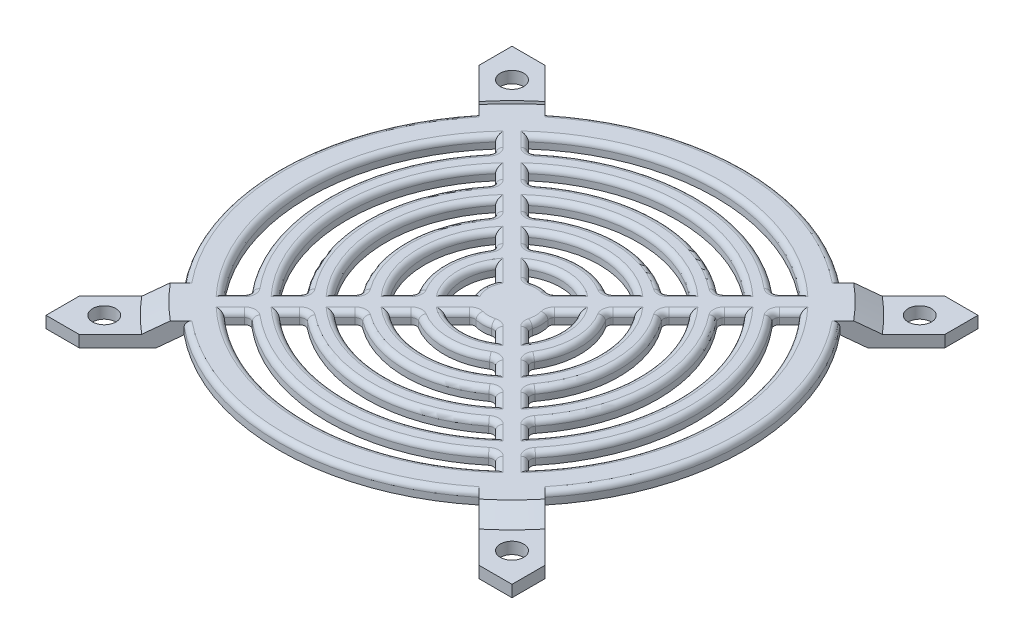
from build123d import *

# Parameters (mm, degrees)
SKETCH_1_R          = 3
EXTRUDE_1_DEPTH     = 6
SKETCH_2_R          = 65
CUT_EXTRUDE_1_DEPTH = 3
CUT_EXTRUDE_1_DRAFT = -60
SKETCH_3_OUTSIDE_W  = 166.354
SKETCH_3_OUTSIDE_H  = 166.354
SKETCH_3_OUTSIDE_R  = 62.5
CUT_EXTRUDE_2_DEPTH = 3
CUT_EXTRUDE_2_DRAFT = -60
FILLET_1_R          = 1.4


with BuildPart() as part:
    # Эскиз1 → Бобышка-Вытянуть1 (new body)
    with BuildSketch(Plane(origin=(0, 0, 0), x_dir=(1, 0, 0), z_dir=(0, 1, 0))):
        with BuildLine():
            Line((-51.514718626, -60), (-37.971101151, -46.456382526))
            ThreePointArc((-37.971101151, -46.456382526), (0, -60), (37.971101151, -46.456382526))
            Line((37.971101151, -46.456382526), (51.514718626, -60))
            Line((51.514718626, -60), (60, -60))
            Line((60, -60), (60, -51.514718626))
            Line((60, -51.514718626), (46.456382526, -37.971101151))
            ThreePointArc((46.456382526, -37.971101151), (60, 0), (46.456382526, 37.971101151))
            Line((46.456382526, 37.971101151), (60, 51.514718626))
            Line((60, 51.514718626), (60, 60))
            Line((60, 60), (51.514718626, 60))
            Line((51.514718626, 60), (37.971101151, 46.456382526))
            ThreePointArc((37.971101151, 46.456382526), (0, 60), (-37.971101151, 46.456382526))
            Line((-37.971101151, 46.456382526), (-51.514718626, 60))
            Line((-51.514718626, 60), (-60, 60))
            Line((-60, 60), (-60, 51.514718626))
            Line((-60, 51.514718626), (-46.456382526, 37.971101151))
            ThreePointArc((-46.456382526, 37.971101151), (-60, 0), (-46.456382526, -37.971101151))
            Line((-46.456382526, -37.971101151), (-60, -51.514718626))
            Line((-60, -51.514718626), (-60, -60))
            Line((-60, -60), (-51.514718626, -60))
        make_face()
        with Locations(Location((-52.5, -52.5, 0), (0, 0, 270))):
            Circle(SKETCH_1_R, mode=Mode.SUBTRACT)
        with Locations(Location((-52.5, 52.5, 0), (0, 0, 270))):
            Circle(SKETCH_1_R, mode=Mode.SUBTRACT)
        with Locations(Location((52.5, 52.5, 0), (0, 0, 270))):
            Circle(SKETCH_1_R, mode=Mode.SUBTRACT)
        with Locations(Location((52.5, -52.5, 0), (0, 0, 270))):
            Circle(SKETCH_1_R, mode=Mode.SUBTRACT)
        with BuildLine():
            Line((14.312505684, 10.069864997), (17.889167375, 13.646526688))
            ThreePointArc((17.889167375, 13.646526688), (22.5, 0), (17.889167375, -13.646526688))
            Line((17.889167375, -13.646526688), (14.312505684, -10.069864997))
            ThreePointArc((14.312505684, -10.069864997), (17.5, 0), (14.312505684, 10.069864997))
        make_face(mode=Mode.SUBTRACT)
        with BuildLine():
            Line((2.73923518, -6.981875867), (6.459180807, -10.701821494))
            ThreePointArc((6.459180807, -10.701821494), (0, -12.5), (-6.459180807, -10.701821494))
            Line((-6.459180807, -10.701821494), (-2.73923518, -6.981875867))
            ThreePointArc((-2.73923518, -6.981875867), (0, -7.5), (2.73923518, -6.981875867))
        make_face(mode=Mode.SUBTRACT)
        with BuildLine():
            Line((6.981875867, -2.73923518), (10.701821494, -6.459180807))
            ThreePointArc((10.701821494, -6.459180807), (12.5, 0), (10.701821494, 6.459180807))
            Line((10.701821494, 6.459180807), (6.981875867, 2.73923518))
            ThreePointArc((6.981875867, 2.73923518), (7.5, 0), (6.981875867, -2.73923518))
        make_face(mode=Mode.SUBTRACT)
        with BuildLine():
            Line((2.73923518, 6.981875867), (6.459180807, 10.701821494))
            ThreePointArc((6.459180807, 10.701821494), (0, 12.5), (-6.459180807, 10.701821494))
            Line((-6.459180807, 10.701821494), (-2.73923518, 6.981875867))
            ThreePointArc((-2.73923518, 6.981875867), (0, 7.5), (2.73923518, 6.981875867))
        make_face(mode=Mode.SUBTRACT)
        with BuildLine():
            Line((10.069864997, 14.312505684), (13.646526688, 17.889167375))
            ThreePointArc((13.646526688, 17.889167375), (0, 22.5), (-13.646526688, 17.889167375))
            Line((-13.646526688, 17.889167375), (-10.069864997, 14.312505684))
            ThreePointArc((-10.069864997, 14.312505684), (0, 17.5), (10.069864997, 14.312505684))
        make_face(mode=Mode.SUBTRACT)
        with BuildLine():
            Line((-10.701821494, 6.459180807), (-6.981875867, 2.73923518))
            ThreePointArc((-6.981875867, 2.73923518), (-7.5, 0), (-6.981875867, -2.73923518))
            Line((-6.981875867, -2.73923518), (-10.701821494, -6.459180807))
            ThreePointArc((-10.701821494, -6.459180807), (-12.5, 0), (-10.701821494, 6.459180807))
        make_face(mode=Mode.SUBTRACT)
        with BuildLine():
            Line((10.069864997, -14.312505684), (13.646526688, -17.889167375))
            ThreePointArc((13.646526688, -17.889167375), (0, -22.5), (-13.646526688, -17.889167375))
            Line((-13.646526688, -17.889167375), (-10.069864997, -14.312505684))
            ThreePointArc((-10.069864997, -14.312505684), (0, -17.5), (10.069864997, -14.312505684))
        make_face(mode=Mode.SUBTRACT)
        with BuildLine():
            Line((21.450702124, -17.208061437), (25.004174187, -20.761533499))
            ThreePointArc((25.004174187, -20.761533499), (32.5, 0), (25.004174187, 20.761533499))
            Line((25.004174187, 20.761533499), (21.450702124, 17.208061437))
            ThreePointArc((21.450702124, 17.208061437), (27.5, 0), (21.450702124, -17.208061437))
        make_face(mode=Mode.SUBTRACT)
        with BuildLine():
            Line((28.552835624, -24.310194936), (32.098394917, -27.85575423))
            ThreePointArc((32.098394917, -27.85575423), (42.5, 0), (32.098394917, 27.85575423))
            Line((32.098394917, 27.85575423), (28.552835624, 24.310194936))
            ThreePointArc((28.552835624, 24.310194936), (37.5, 0), (28.552835624, -24.310194936))
        make_face(mode=Mode.SUBTRACT)
        with BuildLine():
            Line((35.641836449, -31.399195762), (39.183767645, -34.941126958))
            ThreePointArc((39.183767645, -34.941126958), (52.5, 0), (39.183767645, 34.941126958))
            Line((39.183767645, 34.941126958), (35.641836449, 31.399195762))
            ThreePointArc((35.641836449, 31.399195762), (47.5, 0), (35.641836449, -31.399195762))
        make_face(mode=Mode.SUBTRACT)
        with BuildLine():
            Line((17.208061437, -21.450702124), (20.761533499, -25.004174187))
            ThreePointArc((20.761533499, -25.004174187), (0, -32.5), (-20.761533499, -25.004174187))
            Line((-20.761533499, -25.004174187), (-17.208061437, -21.450702124))
            ThreePointArc((-17.208061437, -21.450702124), (0, -27.5), (17.208061437, -21.450702124))
        make_face(mode=Mode.SUBTRACT)
        with BuildLine():
            Line((24.310194936, -28.552835624), (27.85575423, -32.098394917))
            ThreePointArc((27.85575423, -32.098394917), (0, -42.5), (-27.85575423, -32.098394917))
            Line((-27.85575423, -32.098394917), (-24.310194936, -28.552835624))
            ThreePointArc((-24.310194936, -28.552835624), (0, -37.5), (24.310194936, -28.552835624))
        make_face(mode=Mode.SUBTRACT)
        with BuildLine():
            Line((31.399195762, -35.641836449), (34.941126958, -39.183767645))
            ThreePointArc((34.941126958, -39.183767645), (0, -52.5), (-34.941126958, -39.183767645))
            Line((-34.941126958, -39.183767645), (-31.399195762, -35.641836449))
            ThreePointArc((-31.399195762, -35.641836449), (0, -47.5), (31.399195762, -35.641836449))
        make_face(mode=Mode.SUBTRACT)
        with BuildLine():
            Line((-32.098394917, -27.85575423), (-28.552835624, -24.310194936))
            ThreePointArc((-28.552835624, -24.310194936), (-37.5, 0), (-28.552835624, 24.310194936))
            Line((-28.552835624, 24.310194936), (-32.098394917, 27.85575423))
            ThreePointArc((-32.098394917, 27.85575423), (-42.5, 0), (-32.098394917, -27.85575423))
        make_face(mode=Mode.SUBTRACT)
        with BuildLine():
            Line((-25.004174187, -20.761533499), (-21.450702124, -17.208061437))
            ThreePointArc((-21.450702124, -17.208061437), (-27.5, 0), (-21.450702124, 17.208061437))
            Line((-21.450702124, 17.208061437), (-25.004174187, 20.761533499))
            ThreePointArc((-25.004174187, 20.761533499), (-32.5, 0), (-25.004174187, -20.761533499))
        make_face(mode=Mode.SUBTRACT)
        with BuildLine():
            Line((-17.889167375, -13.646526688), (-14.312505684, -10.069864997))
            ThreePointArc((-14.312505684, -10.069864997), (-17.5, 0), (-14.312505684, 10.069864997))
            Line((-14.312505684, 10.069864997), (-17.889167375, 13.646526688))
            ThreePointArc((-17.889167375, 13.646526688), (-22.5, 0), (-17.889167375, -13.646526688))
        make_face(mode=Mode.SUBTRACT)
        with BuildLine():
            Line((-20.761533499, 25.004174187), (-17.208061437, 21.450702124))
            ThreePointArc((-17.208061437, 21.450702124), (0, 27.5), (17.208061437, 21.450702124))
            Line((17.208061437, 21.450702124), (20.761533499, 25.004174187))
            ThreePointArc((20.761533499, 25.004174187), (0, 32.5), (-20.761533499, 25.004174187))
        make_face(mode=Mode.SUBTRACT)
        with BuildLine():
            Line((-27.85575423, 32.098394917), (-24.310194936, 28.552835624))
            ThreePointArc((-24.310194936, 28.552835624), (0, 37.5), (24.310194936, 28.552835624))
            Line((24.310194936, 28.552835624), (27.85575423, 32.098394917))
            ThreePointArc((27.85575423, 32.098394917), (0, 42.5), (-27.85575423, 32.098394917))
        make_face(mode=Mode.SUBTRACT)
        with BuildLine():
            Line((31.399195762, 35.641836449), (34.941126958, 39.183767645))
            ThreePointArc((34.941126958, 39.183767645), (0, 52.5), (-34.941126958, 39.183767645))
            Line((-34.941126958, 39.183767645), (-31.399195762, 35.641836449))
            ThreePointArc((-31.399195762, 35.641836449), (0, 47.5), (31.399195762, 35.641836449))
        make_face(mode=Mode.SUBTRACT)
        with BuildLine():
            Line((-39.183767645, 34.941126958), (-35.641836449, 31.399195762))
            ThreePointArc((-35.641836449, 31.399195762), (-47.5, 0), (-35.641836449, -31.399195762))
            Line((-35.641836449, -31.399195762), (-39.183767645, -34.941126958))
            ThreePointArc((-39.183767645, -34.941126958), (-52.5, 0), (-39.183767645, 34.941126958))
        make_face(mode=Mode.SUBTRACT)
    extrude(amount=EXTRUDE_1_DEPTH)


with BuildPart() as cut_extrude_1_tool:
    # Эскиз2 → Вырез-Вытянуть1 (with draft: the straight prism first)
    with BuildSketch(Plane.XZ):
        Circle(SKETCH_2_R)
    extrude(amount=-CUT_EXTRUDE_1_DEPTH)
    # Вырез-Вытянуть1: the draft: its side faces are tilted about the plane it starts from
    cut_extrude_1_sides = [cut_extrude_1_tool.faces().sort_by_distance(p)[0] for p in [
        (-65, 1.5, 0),
    ]]
    draft(cut_extrude_1_sides, Plane.XZ, CUT_EXTRUDE_1_DRAFT)


with BuildPart() as part_1:
    add(part.part)

    # Вырез-Вытянуть1: cut by cut_extrude_1_tool
    add(cut_extrude_1_tool.part, mode=Mode.SUBTRACT)


with BuildPart() as cut_extrude_2_tool:
    # Эскиз3 outside → Вырез-Вытянуть2 (with draft: the straight prism first)
    with BuildSketch(Plane(origin=(0, 6, 0), x_dir=(1, 0, 0), z_dir=(0, 1, 0))):
        Rectangle(SKETCH_3_OUTSIDE_W, SKETCH_3_OUTSIDE_H)
        Circle(SKETCH_3_OUTSIDE_R, mode=Mode.SUBTRACT)
    extrude(amount=-CUT_EXTRUDE_2_DEPTH)
    # Вырез-Вытянуть2: the draft: its side faces are tilted about the plane it starts from
    cut_extrude_2_sides = [cut_extrude_2_tool.faces().sort_by_distance(p)[0] for p in [
        (0, 4.5, 83.177),
        (83.177, 4.5, 0),
        (0, 4.5, -83.177),
        (-83.177, 4.5, 0),
        (-62.5, 4.5, 0),
    ]]
    draft(cut_extrude_2_sides, Plane(origin=(0, 6, 0), x_dir=(1, 0, 0), z_dir=(0, 1, 0)), CUT_EXTRUDE_2_DRAFT)


with BuildPart() as part_2:
    add(part_1.part)

    # Вырез-Вытянуть2: cut by cut_extrude_2_tool
    add(cut_extrude_2_tool.part, mode=Mode.SUBTRACT)

    # Скругление1
    fillet_1_edges = [part_2.edges().sort_by_distance(p)[0] for p in [
        (24.310194936, 4.5, 28.552835624),
        (-24.310194936, 4.5, 28.552835624),
        (0, 6, 37.5),
        (-26.082974583, 6, 30.32561527),
        (0, 6, 42.5),
        (26.082974583, 6, 30.32561527),
        (31.399195762, 4.5, 35.641836449),
        (-31.399195762, 4.5, 35.641836449),
        (0, 6, 47.5),
        (-33.17016136, 6, 37.412802047),
        (0, 6, 52.5),
        (33.17016136, 6, 37.412802047),
        (-35.641836449, 4.5, 31.399195762),
        (-35.641836449, 4.5, -31.399195762),
        (-52.5, 6, 0),
        (-37.412802047, 6, 33.17016136),
        (60, 6, 0),
        (-47.5, 6, 0),
        (-37.412802047, 6, -33.17016136),
        (-14.312505684, 4.5, 10.069864997),
        (-14.312505684, 4.5, -10.069864997),
        (-17.5, 6, 0),
        (-16.100836529, 6, -11.858195842),
        (-22.5, 6, 0),
        (-16.100836529, 6, 11.858195842),
        (6.981875867, 4.5, -2.73923518),
        (6.981875867, 4.5, 2.73923518),
        (7.5, 6, 0),
        (8.841848681, 6, 4.599207994),
        (12.5, 6, 0),
        (8.841848681, 6, -4.599207994),
        (-21.450702124, 4.5, 17.208061437),
        (-21.450702124, 4.5, -17.208061437),
        (-27.5, 6, 0),
        (-23.227438155, 6, -18.984797468),
        (-32.5, 6, 0),
        (-23.227438155, 6, 18.984797468),
        (-2.73923518, 4.5, -6.981875867),
        (2.73923518, 4.5, -6.981875867),
        (0, 6, -7.5),
        (4.599207994, 6, -8.841848681),
        (0, 6, -12.5),
        (-4.599207994, 6, -8.841848681),
        (-28.552835624, 4.5, 24.310194936),
        (-28.552835624, 4.5, -24.310194936),
        (-37.5, 6, 0),
        (-30.32561527, 6, -26.082974583),
        (-42.5, 6, 0),
        (-30.32561527, 6, 26.082974583),
        (14.312505684, 4.5, -10.069864997),
        (14.312505684, 4.5, 10.069864997),
        (17.5, 6, 0),
        (16.100836529, 6, 11.858195842),
        (22.5, 6, 0),
        (16.100836529, 6, -11.858195842),
        (21.450702124, 4.5, -17.208061437),
        (21.450702124, 4.5, 17.208061437),
        (27.5, 6, 0),
        (23.227438155, 6, 18.984797468),
        (32.5, 6, 0),
        (23.227438155, 6, -18.984797468),
        (-10.069864997, 4.5, -14.312505684),
        (10.069864997, 4.5, -14.312505684),
        (0, 6, -17.5),
        (11.858195842, 6, -16.100836529),
        (0, 6, -22.5),
        (-11.858195842, 6, -16.100836529),
        (28.552835624, 4.5, -24.310194936),
        (28.552835624, 4.5, 24.310194936),
        (37.5, 6, 0),
        (30.32561527, 6, 26.082974583),
        (42.5, 6, 0),
        (30.32561527, 6, -26.082974583),
        (-17.208061437, 4.5, -21.450702124),
        (17.208061437, 4.5, -21.450702124),
        (0, 6, -27.5),
        (18.984797468, 6, -23.227438155),
        (0, 6, -32.5),
        (-18.984797468, 6, -23.227438155),
        (0, 6, -60),
        (35.641836449, 4.5, -31.399195762),
        (35.641836449, 4.5, 31.399195762),
        (47.5, 6, 0),
        (37.412802047, 6, 33.17016136),
        (52.5, 6, 0),
        (37.412802047, 6, -33.17016136),
        (-24.310194936, 4.5, -28.552835624),
        (24.310194936, 4.5, -28.552835624),
        (0, 6, -37.5),
        (26.082974583, 6, -30.32561527),
        (0, 6, -42.5),
        (-26.082974583, 6, -30.32561527),
        (-31.399195762, 4.5, -35.641836449),
        (31.399195762, 4.5, -35.641836449),
        (0, 6, -47.5),
        (33.17016136, 6, -37.412802047),
        (0, 6, -52.5),
        (-33.17016136, 6, -37.412802047),
        (-60, 6, 0),
        (-12.5, 6, 0),
        (-8.841848681, 6, 4.599207994),
        (-7.5, 6, 0),
        (-8.841848681, 6, -4.599207994),
        (0, 6, 60),
        (2.73923518, 4.5, 6.981875867),
        (-2.73923518, 4.5, 6.981875867),
        (0, 6, 12.5),
        (4.599207994, 6, 8.841848681),
        (0, 6, 7.5),
        (-4.599207994, 6, 8.841848681),
        (10.069864997, 4.5, 14.312505684),
        (-10.069864997, 4.5, 14.312505684),
        (0, 6, 17.5),
        (-11.858195842, 6, 16.100836529),
        (0, 6, 22.5),
        (11.858195842, 6, 16.100836529),
        (17.208061437, 4.5, 21.450702124),
        (-17.208061437, 4.5, 21.450702124),
        (0, 6, 27.5),
        (-18.984797468, 6, 23.227438155),
        (0, 6, 32.5),
        (18.984797468, 6, 23.227438155),
    ]]
    fillet(fillet_1_edges, radius=FILLET_1_R)


solid = part_2.part
